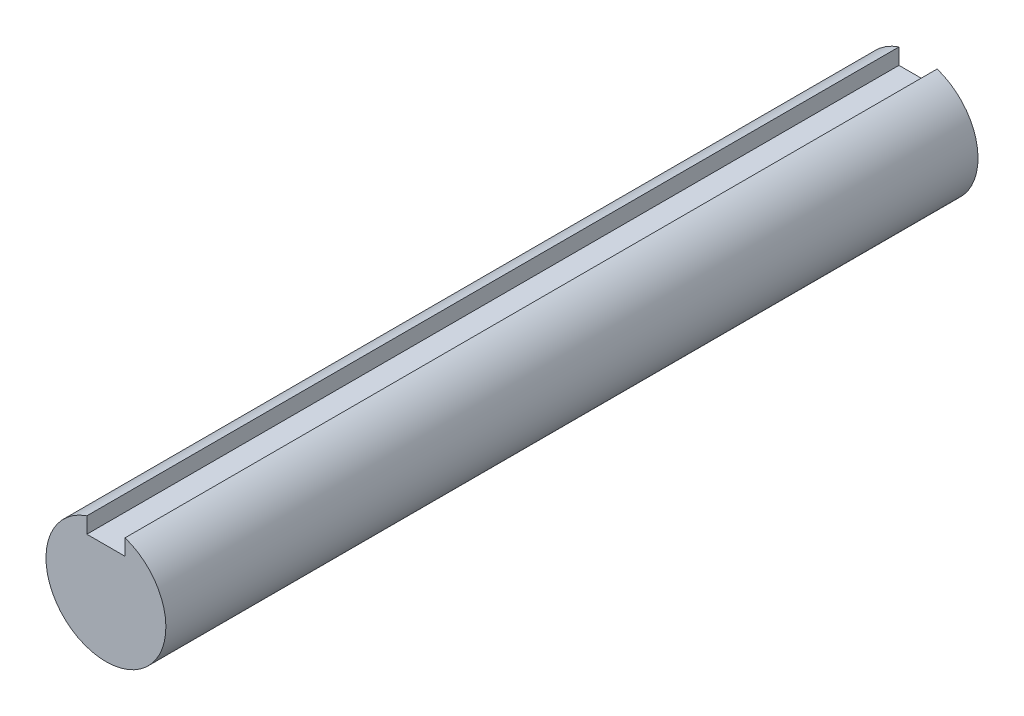
from build123d import *

# Parameters (mm, degrees)
SKETCH1_R           = 7.499985
EXTRUDE1_DEPTH      = 50.8
SKETCH3_W           = 4.7752
SKETCH3_H           = 2.82448
EXTRUDE2_DEPTH      = 51.8
EXTRUDE2_DEPTH_BACK = 51.8


with BuildPart() as part:
    # Sketch1 → Extrude1 (new body, symmetric)
    with BuildSketch(Plane.XY):
        Circle(SKETCH1_R)
    extrude(amount=EXTRUDE1_DEPTH, both=True)

    # Sketch3 → Extrude2 (cut, two sides)
    with BuildSketch(Plane.XY) as extrude2_sk:
        with Locations((0, 6.52526)):
            Rectangle(SKETCH3_W, SKETCH3_H)
    extrude(amount=EXTRUDE2_DEPTH, mode=Mode.SUBTRACT)
    extrude(extrude2_sk.sketch, amount=-EXTRUDE2_DEPTH_BACK, mode=Mode.SUBTRACT)


solid = part.part
